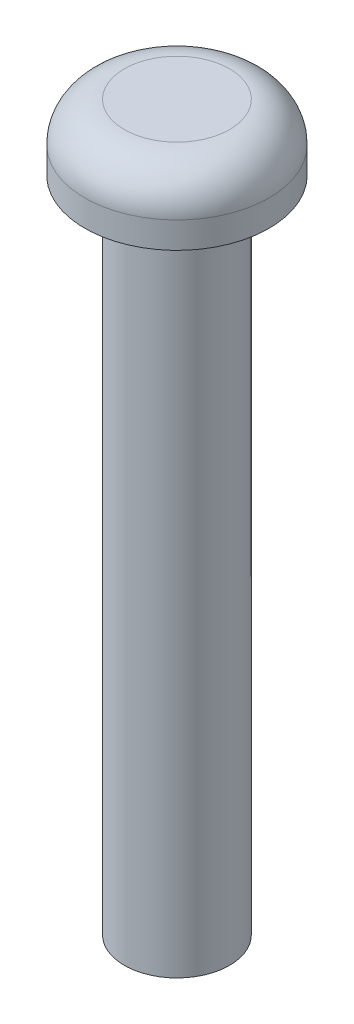
from build123d import *


with BuildPart() as part:
    # Sketch1 → Revolve1 (revolve)
    with BuildSketch(Plane.XY):
        with BuildLine():
            Line((2, 0), (3.5, 0))
            Line((3.5, 0), (3.5, 1))
            ThreePointArc((3.5, 1), (3.060660172, 2.060660172), (2, 2.5))
            Line((2, 2.5), (0, 2.5))
            Line((0, 2.5), (0, -25))
            Line((0, -25), (2, -25))
            Line((2, -25), (2, 0))
        make_face()
    revolve(axis=Axis((0, -25, 0), (0, 1, 0)))


solid = part.part
